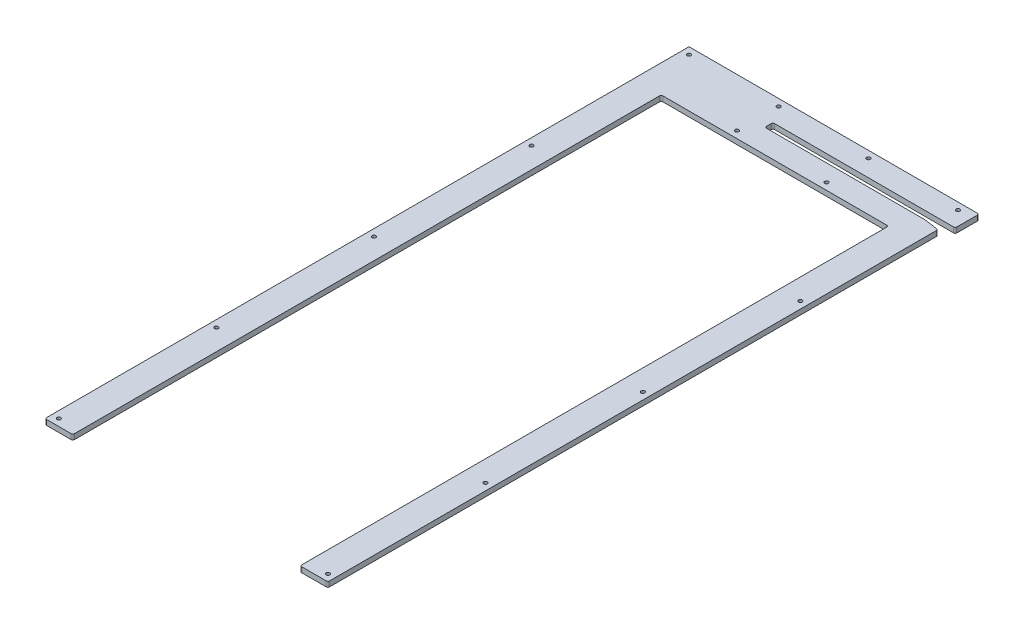
from build123d import *

# Parameters (mm, degrees)
BOSS_EXTRUDE1_DEPTH                                 = 9.525
CSK_FOR_1_4_FLAT_HEAD_MACHINE_SCREW_100_D           = 6.7564
CSK_FOR_1_4_FLAT_HEAD_MACHINE_SCREW_100_CSINK_D     = 17.6447958
CSK_FOR_1_4_FLAT_HEAD_MACHINE_SCREW_100_CSINK_ANGLE = 100
LPATTERN1_COUNT                                     = 2
LPATTERN1_PITCH                                     = 491.2
LPATTERN1_COUNT_DIR2                                = 5
LPATTERN1_PITCH_DIR2                                = 287.65
LPATTERN2_COUNT                                     = 3
LPATTERN2_PITCH                                     = 163.733333333
LPATTERN2_COUNT_DIR2                                = 2
LPATTERN2_PITCH_DIR2                                = 76.2
FILLET1_R                                           = 3.175


with BuildPart() as part:
    # Sketch1 → Boss-Extrude1 (new body)
    with BuildSketch(Plane(origin=(0, 0, 0), x_dir=(1, 0, 0), z_dir=(0, 1, 0))):
        Polygon((-258.3, 0), (-207.5, 0), (-207.5, 1074.4), (207.5, 1074.4), (207.5, 0), (258.3, 0), (258.3, 1113.914856628), (230.3, 1117.85), (-61.7, 1117.85), (-61.7, 1132.55), (271.3, 1132.55), (271.3, 1176), (-258.3, 1176), align=None)
    extrude(amount=BOSS_EXTRUDE1_DEPTH)

    # CSK for 1_4 Flat Head Machine Screw _100 (through all)
    with Locations(Plane.XZ):
        with Locations((-245.6, -1163.3)):
            csk_for_1_4_flat_head_machine_screw_100 = CounterSinkHole(CSK_FOR_1_4_FLAT_HEAD_MACHINE_SCREW_100_D / 2, CSK_FOR_1_4_FLAT_HEAD_MACHINE_SCREW_100_CSINK_D / 2, counter_sink_angle=CSK_FOR_1_4_FLAT_HEAD_MACHINE_SCREW_100_CSINK_ANGLE)

    # LPattern1: CSK for 1_4 Flat Head Machine Screw _100 2 × 5
    with Locations(*[(i * LPATTERN1_PITCH, 0, j * LPATTERN1_PITCH_DIR2) for i in range(LPATTERN1_COUNT) for j in range(LPATTERN1_COUNT_DIR2) if (i, j) != (0, 0)]):
        add(csk_for_1_4_flat_head_machine_screw_100, mode=Mode.SUBTRACT)

    # LPattern2: CSK for 1_4 Flat Head Machine Screw _100 3 × 2, 1 skipped
    with Locations(*[(i * LPATTERN2_PITCH, 0, j * LPATTERN2_PITCH_DIR2) for i in range(LPATTERN2_COUNT) for j in range(LPATTERN2_COUNT_DIR2) if (i, j) not in ((0, 0), (0, 1))]):
        add(csk_for_1_4_flat_head_machine_screw_100, mode=Mode.SUBTRACT)

    # Fillet1
    fillet1_edges = [part.edges().sort_by_distance(p)[0] for p in [
        (-207.5, 4.7625, 0),
        (-258.3, 4.7625, 0),
        (271.3, 4.7625, -1176),
        (271.3, 4.7625, -1132.55),
        (-61.7, 4.7625, -1132.55),
        (-61.7, 4.7625, -1117.85),
        (258.3, 4.7625, -1113.914856628),
        (258.3, 4.7625, 0),
        (207.5, 4.7625, 0),
        (207.5, 4.7625, -1074.4),
        (-207.5, 4.7625, -1074.4),
    ]]
    fillet(fillet1_edges, radius=FILLET1_R)


solid = part.part
